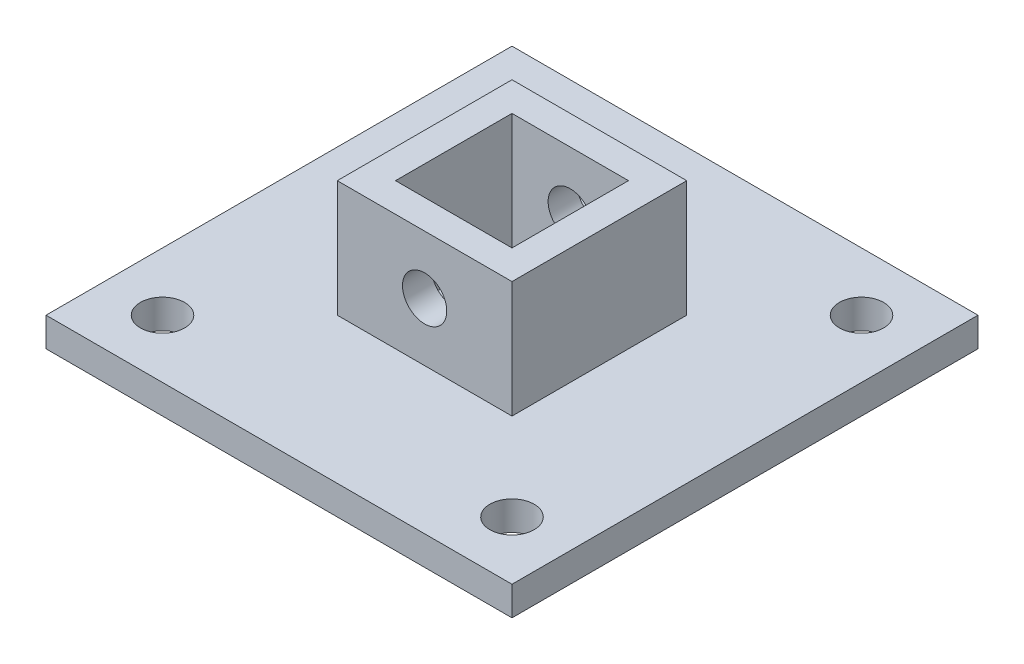
from build123d import *

# Parameters (mm, degrees)
SKETCH1_W               = 101.6
SKETCH1_H               = 101.6
BOSS_EXTRUDE1_DEPTH     = 6.35
SKETCH2_W               = 38.1
SKETCH2_H               = 38.1
SKETCH2_W_2             = 25.4
SKETCH2_H_2             = 25.4
BOSS_EXTRUDE2_DEPTH     = 25.4
SKETCH3_R               = 4.826
CUT_EXTRUDE1_DEPTH      = 32.75
CUT_EXTRUDE1_DEPTH_BACK = 70.85
SKETCH4_R               = 4.826
CUT_EXTRUDE2_DEPTH      = 25.4


with BuildPart() as part:
    # Sketch1 → Boss-Extrude1 (new body)
    with BuildSketch(Plane(origin=(0, 0, 0), x_dir=(1, 0, 0), z_dir=(0, 1, 0))):
        Rectangle(SKETCH1_W, SKETCH1_H)
    extrude(amount=BOSS_EXTRUDE1_DEPTH)

    # Sketch2 → Boss-Extrude2 (add)
    with BuildSketch(Plane(origin=(0, 6.35, 0), x_dir=(1, 0, 0), z_dir=(0, 1, 0))):
        Rectangle(SKETCH2_W, SKETCH2_H)
        Rectangle(SKETCH2_W_2, SKETCH2_H_2, mode=Mode.SUBTRACT)
    extrude(amount=BOSS_EXTRUDE2_DEPTH)

    # Sketch3 → Cut-Extrude1 (cut, two sides)
    with BuildSketch(Plane.XY.offset(19.05)) as cut_extrude1_sk:
        with Locations((0, 19.05)):
            Circle(SKETCH3_R)
    extrude(amount=CUT_EXTRUDE1_DEPTH, mode=Mode.SUBTRACT)
    extrude(cut_extrude1_sk.sketch, amount=-CUT_EXTRUDE1_DEPTH_BACK, mode=Mode.SUBTRACT)

    # Sketch4 → Cut-Extrude2 (cut)
    with BuildSketch(Plane(origin=(0, 6.35, 0), x_dir=(1, 0, 0), z_dir=(0, 1, 0))):
        with Locations((-38.1, 38.1)):
            Circle(SKETCH4_R)
        with Locations((38.1, 38.1)):
            Circle(SKETCH4_R)
        with Locations((38.1, -38.1)):
            Circle(SKETCH4_R)
        with Locations((-38.1, -38.1)):
            Circle(SKETCH4_R)
    extrude(amount=-CUT_EXTRUDE2_DEPTH, mode=Mode.SUBTRACT)


solid = part.part
